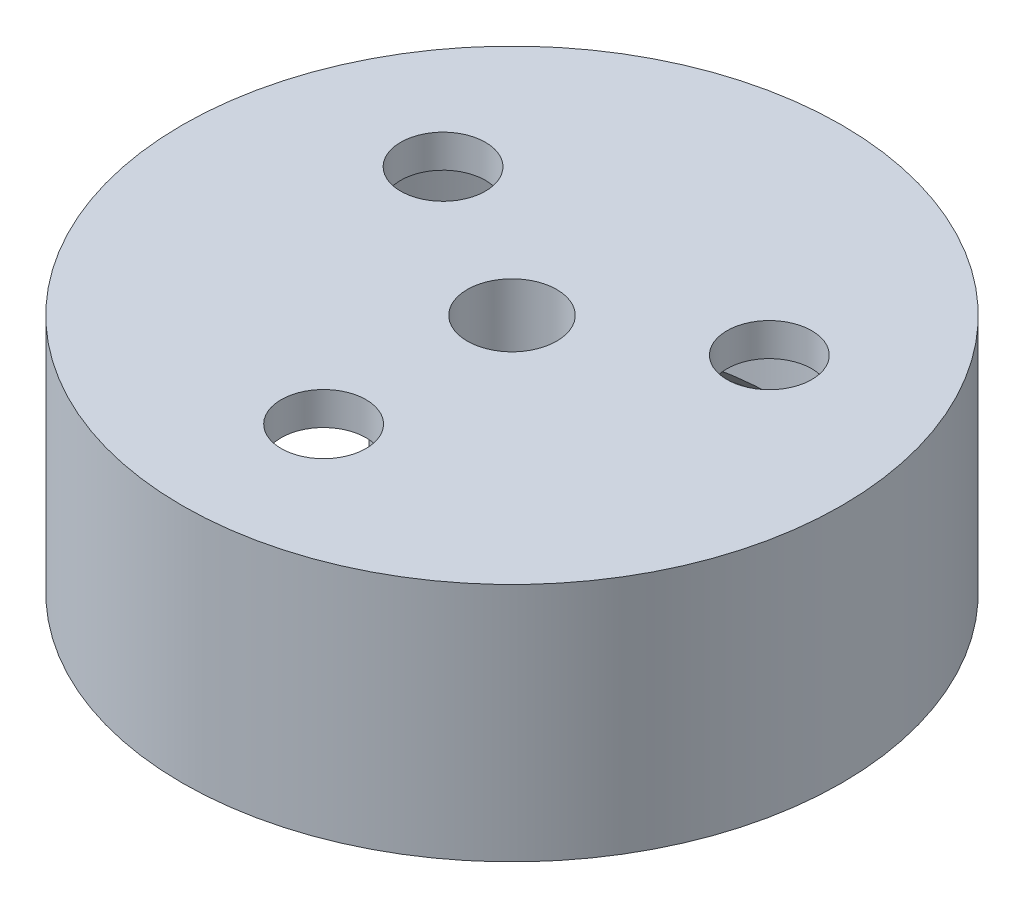
from build123d import *

# Parameters (mm, degrees)
SKETCH_1_R               = 7
EXTRUDE_1_DEPTH          = 5.1
SKETCH_4_R               = 0.95
CUT_EXTRUDE_2_DEPTH      = 8
SKETCH_5_R               = 5.6
SKETCH_5_R_2             = 2.15
CUT_EXTRUDE_3_DEPTH      = 4
SKETCH_6_W               = 3.7
SKETCH_6_H               = 0.8
CUT_EXTRUDE_4_DEPTH      = 4
CHAMFER_1_SIZE           = 0.8
CHAMFER_2_SIZE           = 0.8
SKETCH_7_R               = 1.5
CUT_EXTRUDE_5_DEPTH      = 0.4
SKETCH_8_R               = 0.9
CUT_EXTRUDE_6_DEPTH      = 5
CUT_EXTRUDE_6_DEPTH_BACK = 2.1


with BuildPart() as part:
    # Эскиз1 → Бобышка-Вытянуть1 (new body)
    with BuildSketch(Plane(origin=(0, 0, 0), x_dir=(1, 0, 0), z_dir=(0, 1, 0))):
        Circle(SKETCH_1_R)
    extrude(amount=EXTRUDE_1_DEPTH)

    # Эскиз4 → Вырез-Вытянуть2 (cut)
    with BuildSketch(Plane.XZ):
        Circle(SKETCH_4_R)
    extrude(amount=-CUT_EXTRUDE_2_DEPTH, mode=Mode.SUBTRACT)

    # Эскиз5 → Вырез-Вытянуть3 (cut)
    with BuildSketch(Plane(origin=(0, 0, 0), x_dir=(-1, 0, 0), z_dir=(0, -1, 0))):
        Circle(SKETCH_5_R)
        Circle(SKETCH_5_R_2, mode=Mode.SUBTRACT)
    extrude(amount=-CUT_EXTRUDE_3_DEPTH, mode=Mode.SUBTRACT)

    # Эскиз6 → Вырез-Вытянуть4 (cut)
    with BuildSketch(Plane.XZ):
        with Locations((0, 5.9)):
            Rectangle(SKETCH_6_W, SKETCH_6_H)
    extrude(amount=-CUT_EXTRUDE_4_DEPTH, mode=Mode.SUBTRACT)

    # Фаска1
    chamfer_1_edges = [part.edges().sort_by_distance(p)[0] for p in [
        (2.15, 0, 0),
    ]]
    chamfer(chamfer_1_edges, length=CHAMFER_1_SIZE)

    # Фаска2
    chamfer_2_edges = [part.edges().sort_by_distance(p)[0] for p in [
        (0, 0, -5.6),
    ]]
    chamfer(chamfer_2_edges, length=CHAMFER_2_SIZE)

    # Эскиз7 → Вырез-Вытянуть5 (cut)
    with BuildSketch(Plane.XZ.offset(-4)):
        with Locations((0, 4)):
            Circle(SKETCH_7_R)
        with Locations((3.464101615, -2)):
            Circle(SKETCH_7_R)
        with Locations((-3.464101615, -2)):
            Circle(SKETCH_7_R)
    extrude(amount=-CUT_EXTRUDE_5_DEPTH, mode=Mode.SUBTRACT)

    # Эскиз8 → Вырез-Вытянуть6 (cut, two sides)
    with BuildSketch(Plane.XZ.offset(-4)) as cut_extrude_6_sk:
        with Locations((0, 4)):
            Circle(SKETCH_8_R)
        with Locations((3.464101615, -2)):
            Circle(SKETCH_8_R)
        with Locations((-3.464101615, -2)):
            Circle(SKETCH_8_R)
    extrude(amount=CUT_EXTRUDE_6_DEPTH, mode=Mode.SUBTRACT)
    extrude(cut_extrude_6_sk.sketch, amount=-CUT_EXTRUDE_6_DEPTH_BACK, mode=Mode.SUBTRACT)


solid = part.part
